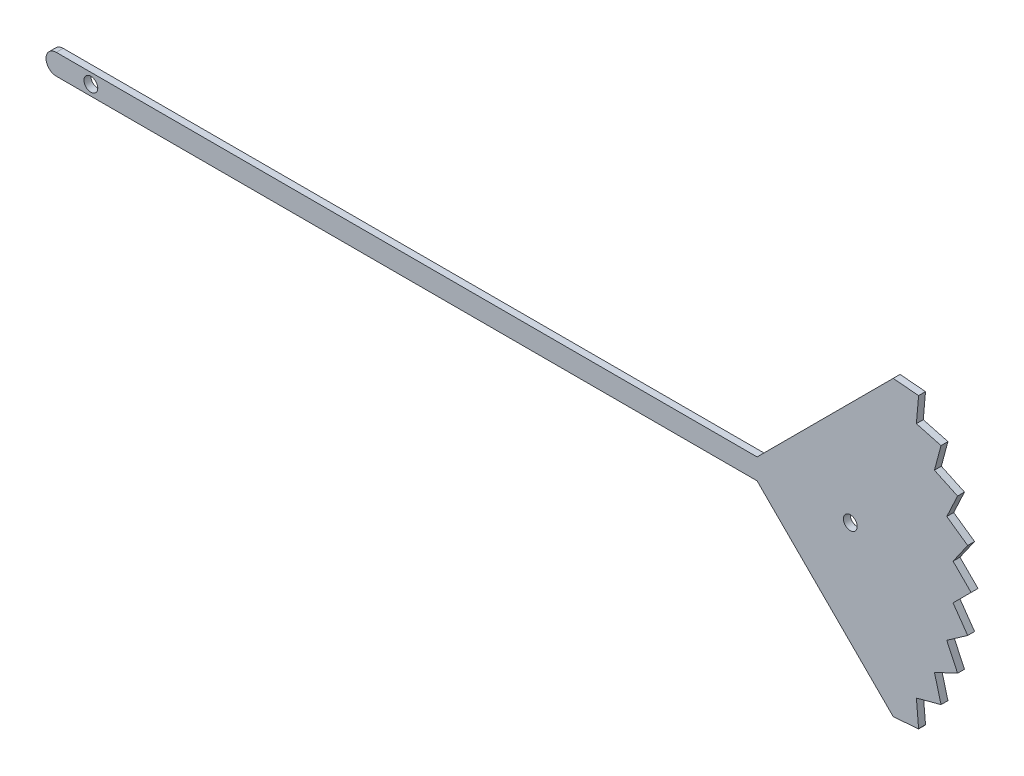
from build123d import *

# Parameters (mm, degrees)
SKETCH_1_R      = 2
EXTRUDE_1_DEPTH = 1


with BuildPart() as part:
    # 草图1 → 凸台-拉伸1 (new, symmetric)
    with BuildSketch(Plane.XY):
        with BuildLine():
            ThreePointArc((-62.732371345, 3), (-65.712136607, 0), (-62.732371345, -3))
            Line((-62.732371345, -3), (-62.69176446, -3))
            Line((-62.69176446, -3), (140.287932097, -3))
            Line((140.287932097, -3), (179.714338968, -42.426406871))
            Line((179.714338968, -42.426406871), (187.058698637, -41.880427348))
            Line((187.058698637, -41.880427348), (187.0808209, -41.78119463))
            Line((187.0808209, -41.78119463), (186.437054755, -34.414586181))
            Line((186.437054755, -34.414586181), (193.579583343, -32.5))
            Line((193.579583343, -32.5), (191.666399319, -25.357095704))
            Line((191.666399319, -25.357095704), (198.367952448, -22.231309316))
            Line((198.367952448, -22.231309316), (195.243481675, -15.529142706))
            Line((195.243481675, -15.529142706), (201.300436043, -11.287131548))
            Line((201.300436043, -11.287131548), (197.059613983, -5.229344565))
            Line((197.059613983, -5.229344565), (202.287932097, 0))
            Line((202.287932097, 0), (197.059613983, 5.229344565))
            Line((197.059613983, 5.229344565), (201.300436043, 11.287131548))
            Line((201.300436043, 11.287131548), (195.243481675, 15.529142706))
            Line((195.243481675, 15.529142706), (198.367952448, 22.231309316))
            Line((198.367952448, 22.231309316), (191.666399319, 25.357095704))
            Line((191.666399319, 25.357095704), (193.579583343, 32.5))
            Line((193.579583343, 32.5), (186.437054755, 34.414586181))
            Line((186.437054755, 34.414586181), (187.0808209, 41.78119463))
            Line((187.0808209, 41.78119463), (179.714338968, 42.426406871))
            Line((179.714338968, 42.426406871), (140.287932097, 3))
            Line((140.287932097, 3), (-62.69176446, 3))
            Line((-62.69176446, 3), (-62.732371345, 3))
        make_face()
        with Locations((-52.712067903, 0)):
            Circle(SKETCH_1_R, mode=Mode.SUBTRACT)
        with Locations((167.287932097, 0)):
            Circle(SKETCH_1_R, mode=Mode.SUBTRACT)
    extrude(amount=EXTRUDE_1_DEPTH, both=True)


solid = part.part
